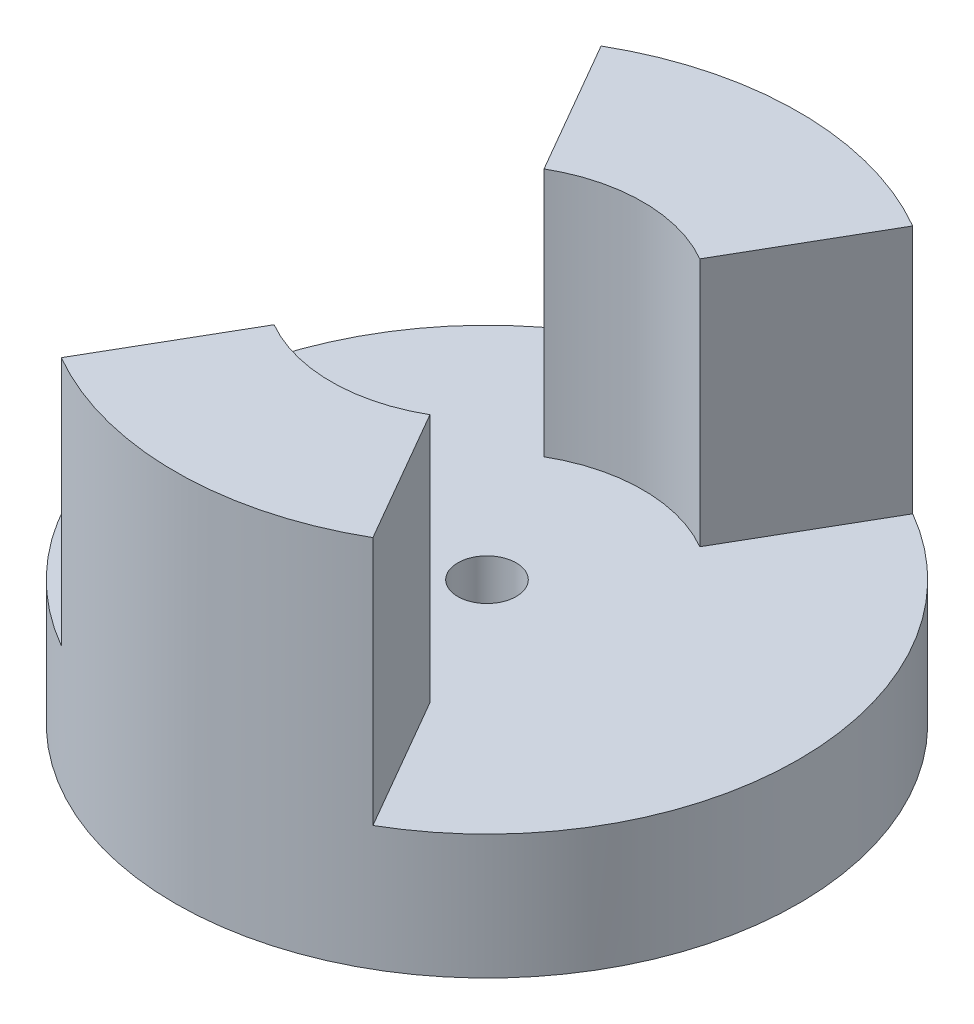
from build123d import *

# Parameters (mm, degrees)
SKETCH1_R             = 6.35
BOSS_EXTRUDE1_DEPTH   = 7.62
F_0_80_TAPPED_HOLE1_D = 1.19126
SKETCH4_R             = 3.175
CUT_EXTRUDE1_DEPTH    = 5.08
CUT_EXTRUDE2_DEPTH    = 5.08


with BuildPart() as part:
    # Sketch1 → Boss-Extrude1 (new body)
    with BuildSketch(Plane(origin=(0, 0, 0), x_dir=(1, 0, 0), z_dir=(0, 1, 0))):
        Circle(SKETCH1_R)
    extrude(amount=BOSS_EXTRUDE1_DEPTH)

    # #0-80 Tapped Hole1 (through all)
    with Locations(Plane(origin=(0, 7.62, 0), x_dir=(1, 0, 0), z_dir=(0, 1, 0))):
        with Locations((0, 0)):
            Hole(F_0_80_TAPPED_HOLE1_D / 2)

    # Sketch4 → Cut-Extrude1 (cut)
    with BuildSketch(Plane(origin=(0, 7.62, 0), x_dir=(1, 0, 0), z_dir=(0, 1, 0))):
        Circle(SKETCH4_R)
    extrude(amount=-CUT_EXTRUDE1_DEPTH, mode=Mode.SUBTRACT)

    # Sketch5 → Cut-Extrude2 (cut)
    with BuildSketch(Plane(origin=(0, 7.62, 0), x_dir=(1, 0, 0), z_dir=(0, 1, 0))):
        Polygon((0, 0), (-7.62, -13.198227154), (-7.62, 13.198227154), align=None)
    cut_extrude2 = extrude(amount=-CUT_EXTRUDE2_DEPTH, mode=Mode.SUBTRACT)

    # Mirror1: Cut-Extrude2 across plane
    add(cut_extrude2.mirror(Plane(origin=(0, 0, 0), x_dir=(0, 0, 1), z_dir=(1, 0, 0))), mode=Mode.SUBTRACT)


solid = part.part
